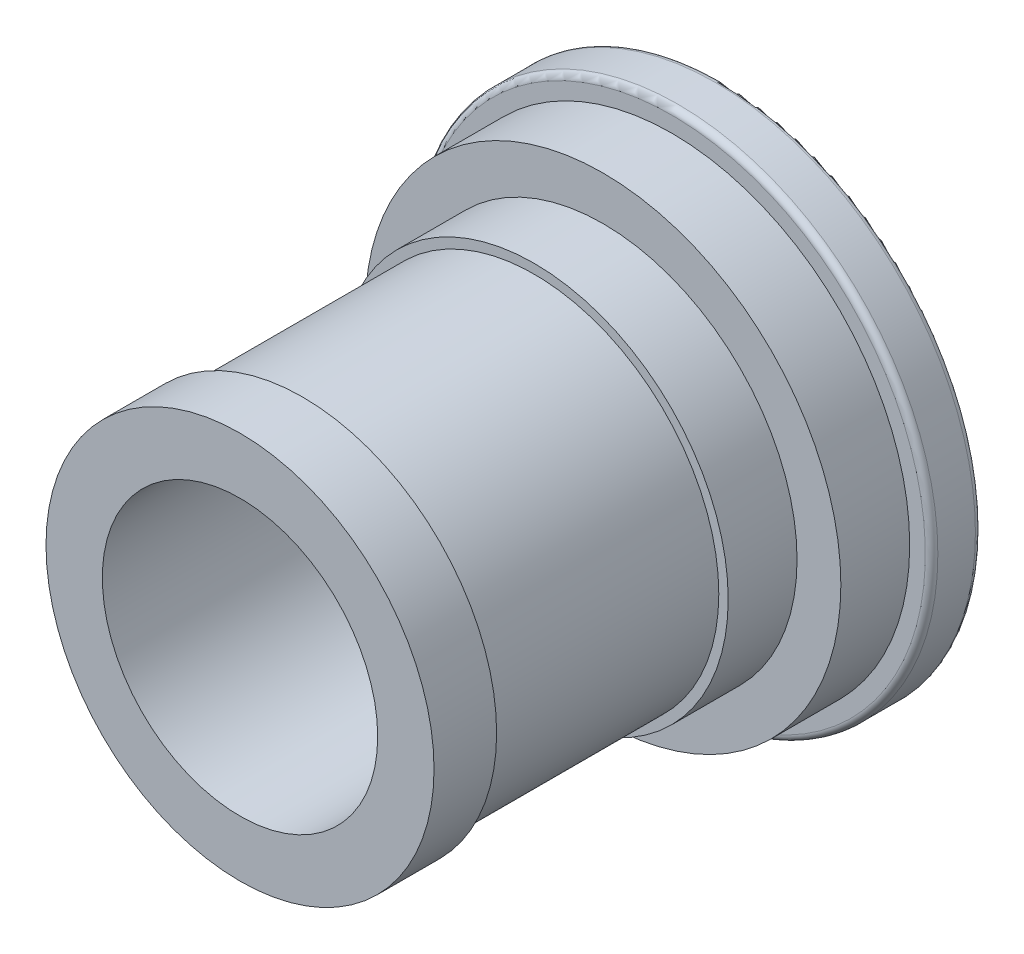
from build123d import *

# Parameters (mm, degrees)
FILLET2_R = 1


with BuildPart() as part:
    # Sketch1 → Revolve1 (revolve)
    with BuildSketch(Plane(origin=(0, 0, 0), x_dir=(1, 0, 0), z_dir=(0, 1, 0)), mode=Mode.PRIVATE) as revolve1_sk:
        Polygon((-41.5, 77), (-22, 77), (-22, 0), (-31, 0), (-31, 10), (-29.5, 10), (-29.5, 47), (-31, 47), (-31, 58), (-38, 58), (-38, 69), (-41.5, 69), align=None)
    revolve(revolve1_sk.sketch.rotate(Axis((0, 0, 0), (0, 0, -1)), 180), axis=Axis((0, 0, 0), (0, 0, -1)))  # turned: the seam where the file's is

    # Fillet2
    fillet2_edges = [part.edges().sort_by_distance(p)[0] for p in [
        (-41.5, 0, -77),
        (-41.5, 0, -69),
    ]]
    fillet(fillet2_edges, radius=FILLET2_R)


solid = part.part
